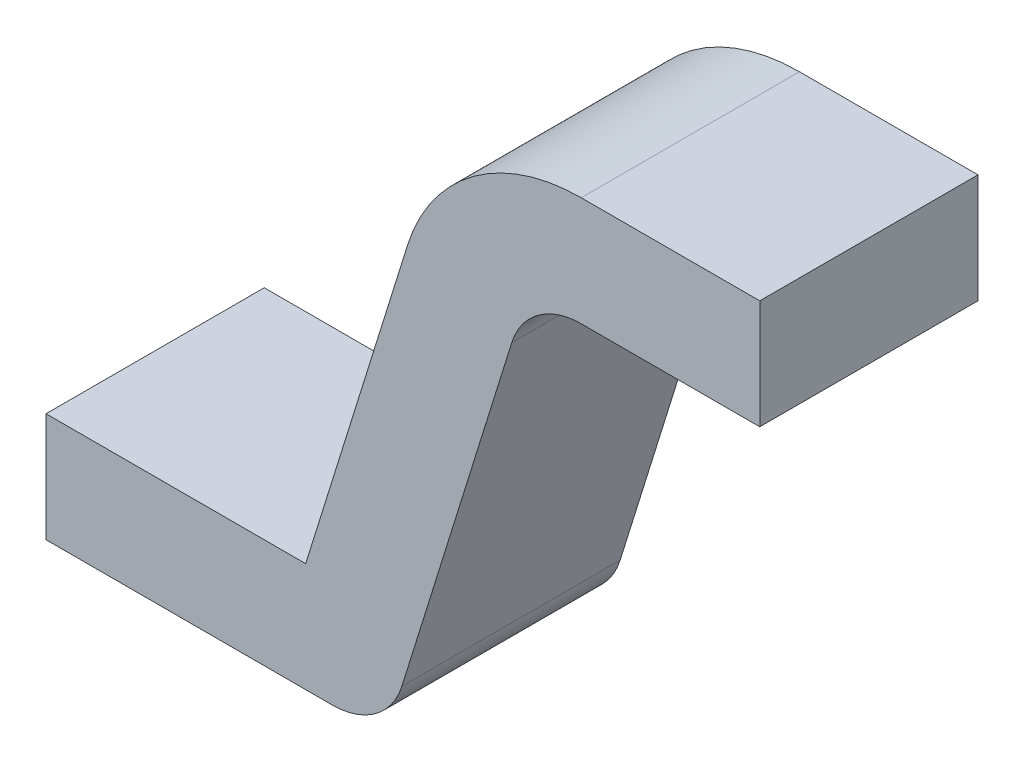
from build123d import *

# Parameters (mm, degrees)
BOSS_EXTRU_1_DEPTH = 0.3


with BuildPart() as part:
    # Esquisse1 → Boss.-Extru.1 (new body)
    with BuildSketch(Plane.XY):
        with BuildLine():
            Line((0, 0), (0.393749669, 0))
            ThreePointArc((0.393749669, 0), (0.45301211, 0.019452107), (0.489218964, 0.070240738))
            Line((0.489218964, 0.070240738), (0.64025091, 0.554759262))
            ThreePointArc((0.64025091, 0.554759262), (0.676457764, 0.605547893), (0.735720205, 0.625))
            Line((0.735720205, 0.625), (0.981168201, 0.625))
            Line((0.981168201, 0.625), (0.981168201, 0.775))
            Line((0.981168201, 0.775), (0.735720205, 0.775))
            ThreePointArc((0.735720205, 0.775), (0.587564103, 0.726369733), (0.497046967, 0.599398154))
            Line((0.497046967, 0.599398154), (0.356962586, 0.15))
            Line((0.356962586, 0.15), (0, 0.15))
            Line((0, 0.15), (0, 0))
        make_face()
    extrude(amount=BOSS_EXTRU_1_DEPTH)


solid = part.part
